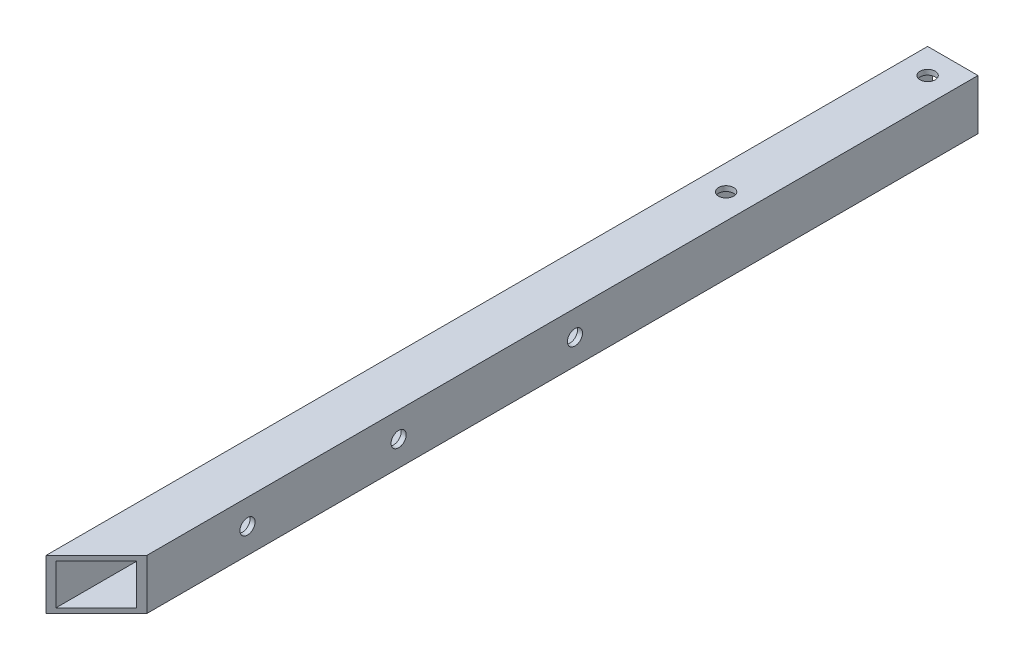
from build123d import *

# Parameters (mm, degrees)
SKETCH_1_W          = 10
SKETCH_1_H          = 10
SKETCH_1_W_2        = 8
SKETCH_1_H_2        = 8
EXTRUDE_1_DEPTH     = 175
SKETCH_2_R          = 1.5
CUT_EXTRUDE_1_DEPTH = 11
SKETCH_3_R          = 1.5
CUT_EXTRUDE_2_DEPTH = 10


with BuildPart() as part:
    # 草图1 → 拉伸-薄壁1 (new body)
    with BuildSketch(Plane.XY):
        Rectangle(SKETCH_1_W, SKETCH_1_H)
        Rectangle(SKETCH_1_W_2, SKETCH_1_H_2, mode=Mode.SUBTRACT)
    extrude(amount=EXTRUDE_1_DEPTH)

    # 草图2 → 切除-拉伸1 (cut, through all)
    with BuildSketch(Plane(origin=(5, 0, 0), x_dir=(0, 0, -1), z_dir=(1, 0, 0))):
        with Locations((-80, 0)):
            Circle(SKETCH_2_R)
        with Locations((-115, 0)):
            Circle(SKETCH_2_R)
        with Locations((-145, 0)):
            Circle(SKETCH_2_R)
    extrude(amount=-CUT_EXTRUDE_1_DEPTH, mode=Mode.SUBTRACT)

    # 草图3 → 切除-拉伸2 (cut)
    with BuildSketch(Plane(origin=(0, 5, 0), x_dir=(1, 0, 0), z_dir=(0, 1, 0))):
        with Locations((0, -5)):
            Circle(SKETCH_3_R)
        with Locations((0, -45)):
            Circle(SKETCH_3_R)
        Polygon((5, -165), (5, -175), (-5, -175), align=None)
    extrude(amount=-CUT_EXTRUDE_2_DEPTH, mode=Mode.SUBTRACT)


solid = part.part
